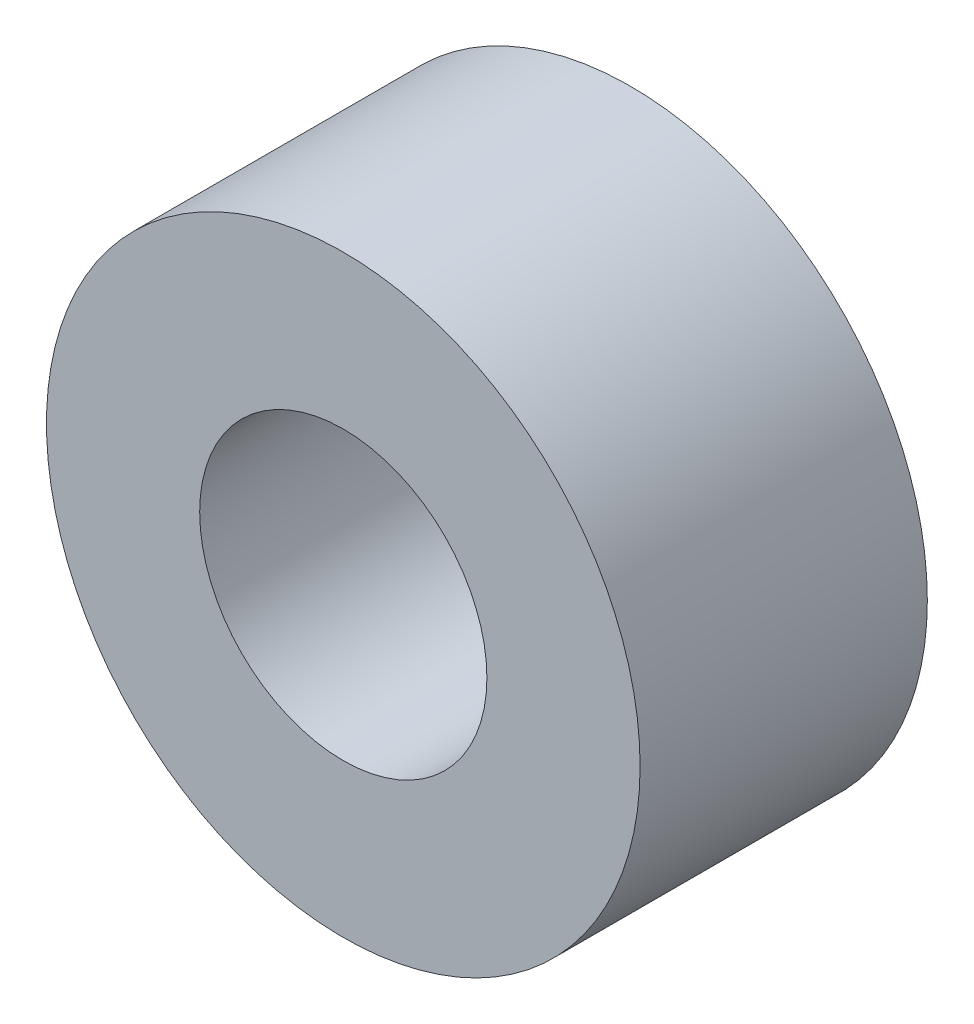
from build123d import *

# Parameters (mm, degrees)
SKETCH2_R           = 3.1
SKETCH2_R_2         = 1.5
BOSS_EXTRUDE5_DEPTH = 3


with BuildPart() as part:
    # Sketch2 → Boss-Extrude5 (new body)
    with BuildSketch(Plane.XY):
        Circle(SKETCH2_R)
        Circle(SKETCH2_R_2, mode=Mode.SUBTRACT)
    extrude(amount=BOSS_EXTRUDE5_DEPTH)


solid = part.part
